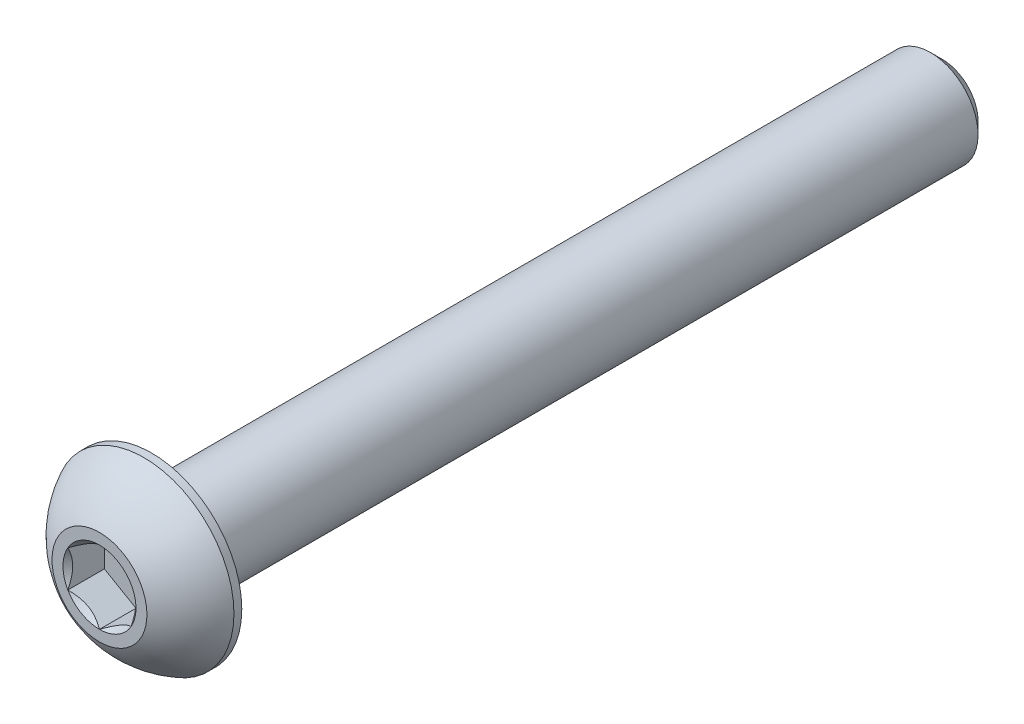
from build123d import *

# Parameters (mm, degrees)
SKETCH1_W          = 25
SKETCH1_H          = 1.5
CHAMFER1_SIZE      = 0.375
CUT_EXTRUDE2_DEPTH = 1.155


with BuildPart() as part:
    # Sketch1 → Revolve1 (revolve)
    with BuildSketch(Plane(origin=(0, 0, 0), x_dir=(0, 0, -1), z_dir=(1, 0, 0))):
        with Locations((14.15, 0.75)):
            Rectangle(SKETCH1_W, SKETCH1_H)
    revolve(axis=Axis((0, 0, -26.65), (0, 0, 1)))

    # Chamfer1
    chamfer1_edges = [part.edges().sort_by_distance(p)[0] for p in [
        (0, -1.5, -26.65),
    ]]
    chamfer(chamfer1_edges, length=CHAMFER1_SIZE)

    # Sketch7 → Revolve2 (revolve)
    with BuildSketch(Plane(origin=(0, 0, 0), x_dir=(0, 0, -1), z_dir=(1, 0, 0))):
        with BuildLine():
            Line((1.4025, 2.85), (1.65, 2.85))
            Line((1.65, 2.85), (1.65, 0))
            Line((1.65, 0), (0, 0))
            Line((0, 0), (0, 1.5))
            ThreePointArc((0, 1.5), (0.59512511, 2.285251969), (1.4025, 2.85))
        make_face()
    revolve(axis=Axis((0, 0, 0), (0, 0, -1)))

    # Sketch5 → Cut-Extrude2 (cut)
    with BuildSketch(Plane.XY):
        Polygon((1, -0.577350269), (1, 0.577350269), (0, 1.154700538), (-1, 0.577350269), (-1, -0.577350269), (0, -1.154700538), align=None)
    extrude(amount=-CUT_EXTRUDE2_DEPTH, mode=Mode.SUBTRACT)

    # Cut-Extrude3 cone 1 section (through the dimple's axis) → Cut-Extrude3 (revolve, cut)
    with BuildSketch(Plane(origin=(0, 0, 0), x_dir=(0, -1, 0), z_dir=(1, 0, 0))):
        Polygon((0, 0), (1.154700538, 0), (0, 1.154700538), align=None)
    revolve(axis=Axis((0, 0, 0), (0, 0, -1)), mode=Mode.SUBTRACT)


solid = part.part
